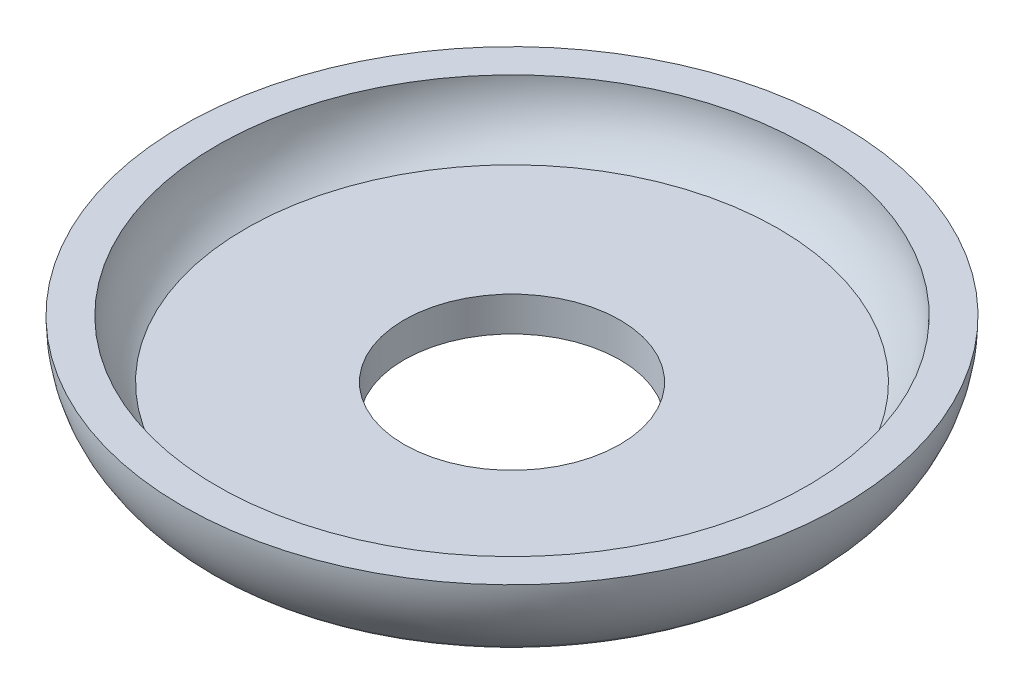
from build123d import *


with BuildPart() as part:
    # Sketch2 → Revolve1 (revolve)
    with BuildSketch(Plane.XY):
        with BuildLine():
            Line((4.7625, 0), (11.371782512, 0))
            ThreePointArc((11.371782512, 0), (12.345828047, 0.194187711), (13.170938407, 0.747058824))
            ThreePointArc((13.170938407, 0.747058824), (14.185363864, 2.26952669), (14.5415, 4.064))
            Line((14.5415, 4.064), (13.0175, 4.064))
            ThreePointArc((13.0175, 4.064), (12.682306331, 2.644096834), (11.7475, 1.524))
            Line((11.7475, 1.524), (4.7625, 1.524))
            Line((4.7625, 1.524), (4.7625, 0))
        make_face()
    revolve(axis=Axis((0, 0, 0), (0, 1, 0)))


solid = part.part
